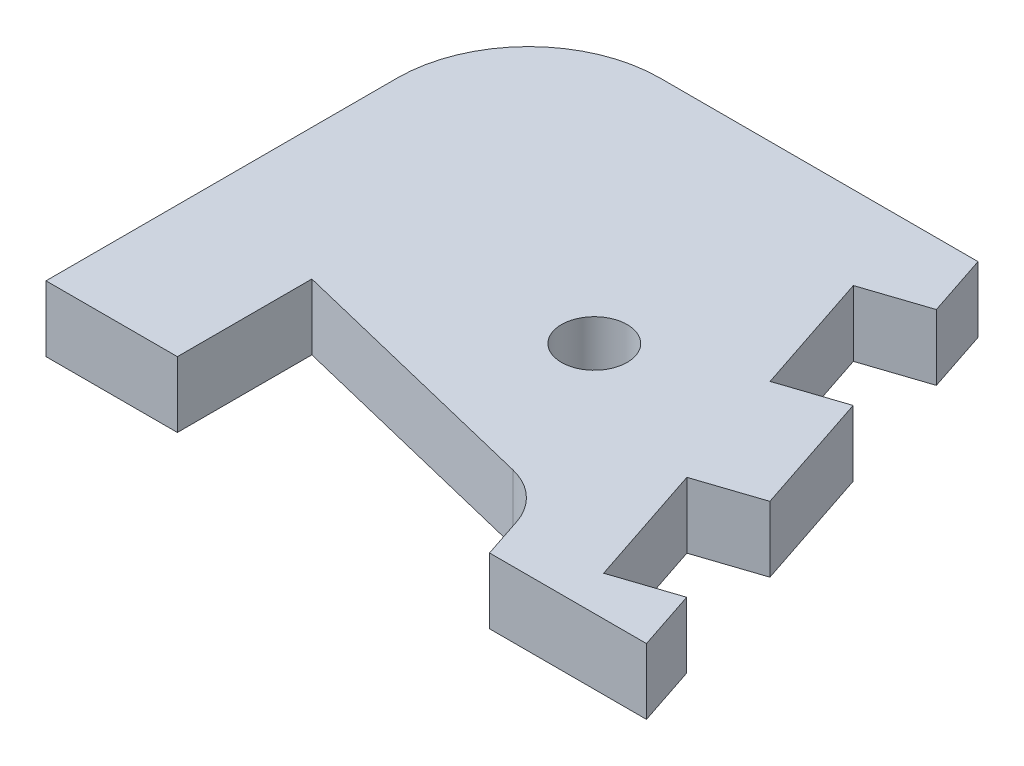
from build123d import *

# Parameters (mm, degrees)
SKETCH1_R           = 5
BOSS_EXTRUDE1_DEPTH = 10
CUT_EXTRUDE1_DEPTH  = 10
FILLET1_R           = 20


with BuildPart() as part:
    # Sketch1 → Boss-Extrude1 (new body)
    with BuildSketch(Plane(origin=(0, 0, 0), x_dir=(1, 0, 0), z_dir=(0, 1, 0))):
        with BuildLine():
            Line((43.536010052, -35.595148029), (18.411320837, 40))
            Line((18.411320837, 40), (-50, 40))
            Line((-50, 40), (-50, -13))
            Line((-50, -13), (-50, -33.474160509))
            Line((-50, -33.474160509), (-30, -33.474160509))
            Line((-30, -33.474160509), (-30, -13))
            Line((-30, -13), (10.471929596, -22.862355971))
            ThreePointArc((10.471929596, -22.862355971), (14.880225334, -25.223606168), (17.593976856, -29.424097387))
            Line((17.593976856, -29.424097387), (19.644977926, -35.595148029))
            Line((19.644977926, -35.595148029), (43.536010052, -35.595148029))
        make_face()
        Circle(SKETCH1_R, mode=Mode.SUBTRACT)
    extrude(amount=BOSS_EXTRUDE1_DEPTH)

    # Sketch2 → Cut-Extrude1 (cut)
    with BuildSketch(Plane(origin=(0, 10, 0), x_dir=(1, 0, 0), z_dir=(0, 1, 0))):
        Polygon((21.565271485, 30.510395408), (12.075666894, 27.35644476), (18.38356819, 8.377235576), (27.873172782, 11.531186225), align=None)
        Polygon((34.181074079, -7.448022959), (24.691469487, -10.601973607), (30.999370784, -29.581182791), (40.488975376, -26.427232142), align=None)
    extrude(amount=-CUT_EXTRUDE1_DEPTH, mode=Mode.SUBTRACT)

    # Fillet1
    fillet1_edges = [part.edges().sort_by_distance(p)[0] for p in [
        (-50, 5, -40),
    ]]
    fillet(fillet1_edges, radius=FILLET1_R)


solid = part.part
